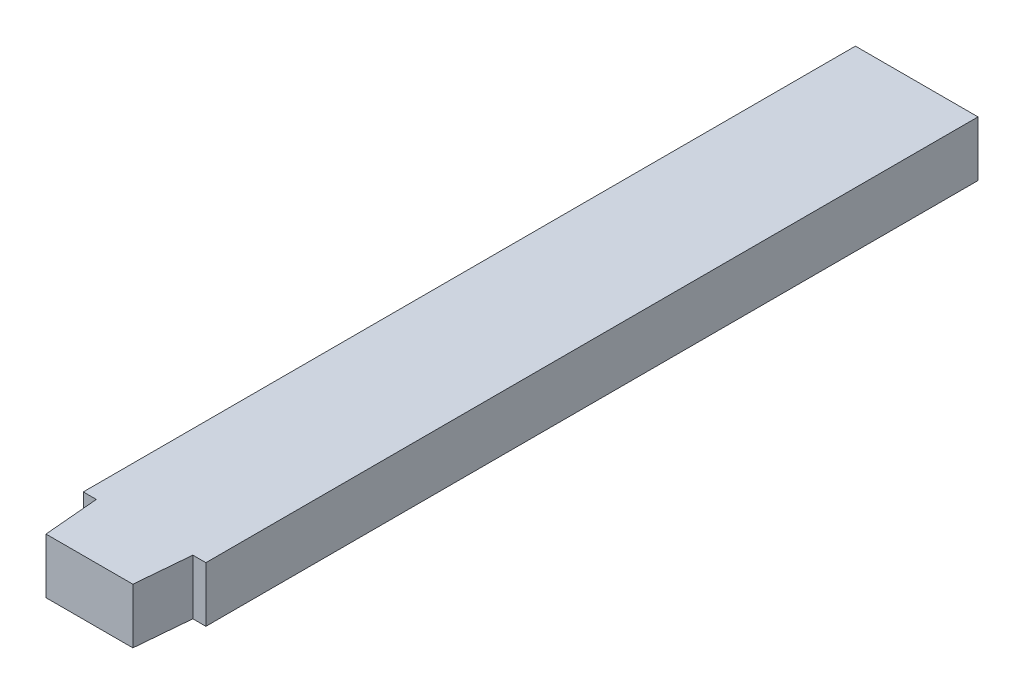
from build123d import *

# Parameters (mm, degrees)
SKETCH1_W           = 12.7
SKETCH1_H           = 80
BOSS_EXTRUDE1_DEPTH = 5.715


with BuildPart() as part:
    # Sketch1 → Boss-Extrude1 (new body)
    with BuildSketch(Plane(origin=(0, 0, 0), x_dir=(1, 0, 0), z_dir=(0, 1, 0))):
        Rectangle(SKETCH1_W, SKETCH1_H)
        Polygon((5, -40), (-5, -40), (-4.5, -45.715), (4.5, -45.715), align=None)
    extrude(amount=BOSS_EXTRUDE1_DEPTH)


solid = part.part
